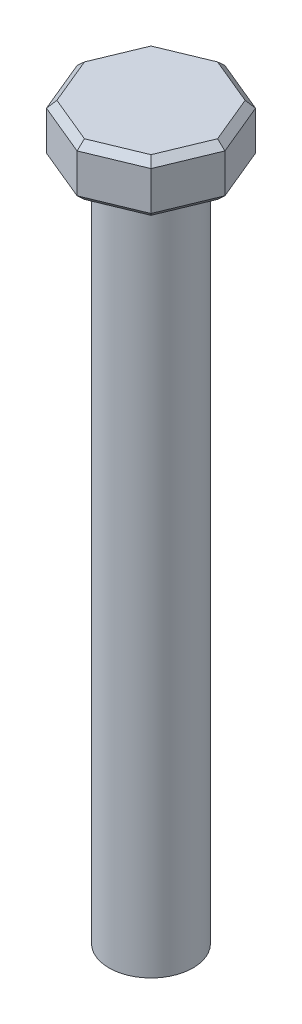
from build123d import *

# Parameters (mm, degrees)
SKETCH1_R           = 4
BOSS_EXTRUDE1_DEPTH = 64.5
BOSS_EXTRUDE2_DEPTH = 5
CHAMFER1_SIZE       = 0.65


with BuildPart() as part:
    # Sketch1 → Boss-Extrude1 (new body)
    with BuildSketch(Plane(origin=(0, 0, 0), x_dir=(1, 0, 0), z_dir=(0, 1, 0))):
        Circle(SKETCH1_R)
    extrude(amount=BOSS_EXTRUDE1_DEPTH)

    # Sketch2 → Boss-Extrude2 (add)
    with BuildSketch(Plane(origin=(0, 64.5, 0), x_dir=(1, 0, 0), z_dir=(0, 1, 0))):
        Polygon((7.035549302, 0), (4.974884621, 4.974884621), (0, 7.035549302), (-4.974884621, 4.974884621), (-7.035549302, 0), (-4.974884621, -4.974884621), (0, -7.035549302), (4.974884621, -4.974884621), align=None)
    extrude(amount=BOSS_EXTRUDE2_DEPTH)

    # Chamfer1
    chamfer1_edges = [part.edges().sort_by_distance(p)[0] for p in [
        (-6.005216961, 69.5, 2.48744231),
        (-2.48744231, 69.5, 6.005216961),
        (2.48744231, 69.5, 6.005216961),
        (6.005216961, 64.5, 2.48744231),
        (6.005216961, 64.5, -2.48744231),
        (2.48744231, 64.5, -6.005216961),
        (-2.48744231, 64.5, -6.005216961),
        (-6.005216961, 64.5, -2.48744231),
        (-6.005216961, 64.5, 2.48744231),
        (-2.48744231, 64.5, 6.005216961),
        (2.48744231, 64.5, 6.005216961),
        (6.005216961, 69.5, 2.48744231),
        (6.005216961, 69.5, -2.48744231),
        (2.48744231, 69.5, -6.005216961),
        (-2.48744231, 69.5, -6.005216961),
        (-6.005216961, 69.5, -2.48744231),
    ]]
    chamfer(chamfer1_edges, length=CHAMFER1_SIZE)


solid = part.part
